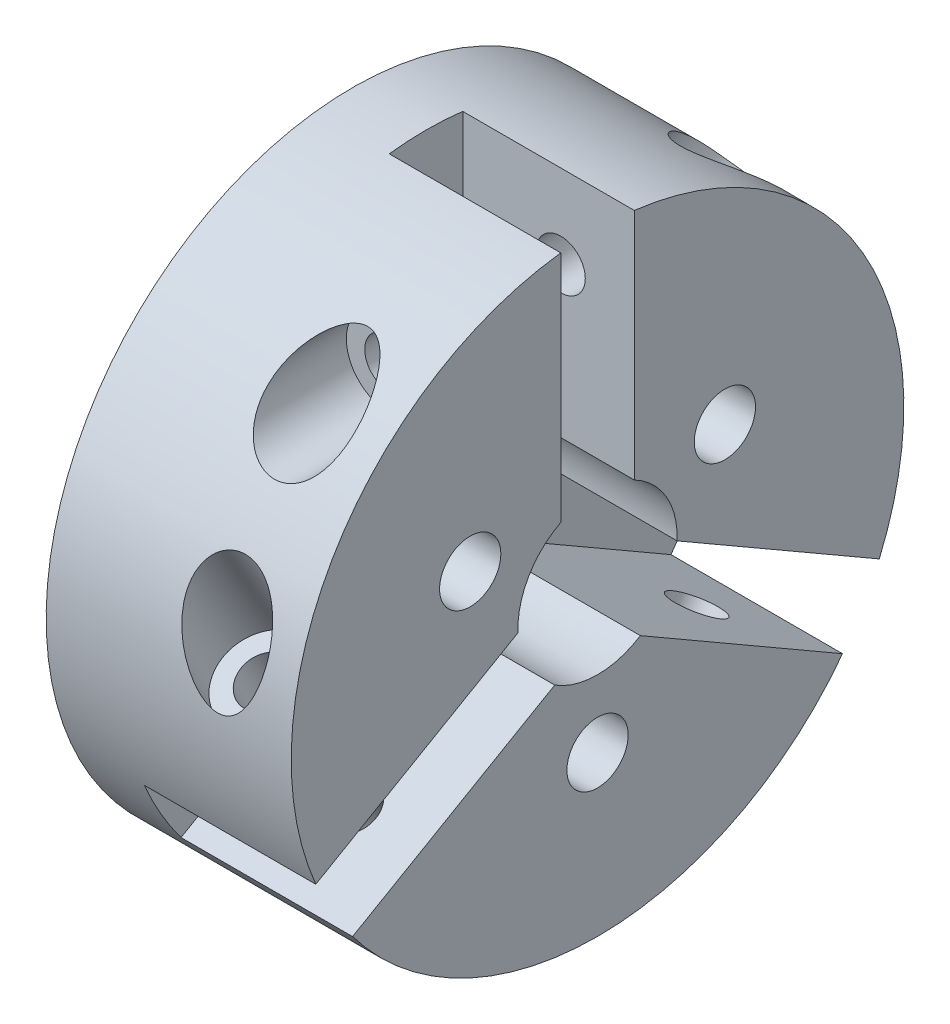
from build123d import *

# Parameters (mm, degrees)
SKETCH1_R           = 12.5
SKETCH1_R_2         = 32.5
BOSS_EXTRUDE1_DEPTH = 30
SKETCH1_3_R         = 12.5
BOSS_EXTRUDE2_DEPTH = 100
SKETCH5_R           = 10
SKETCH5_R_2         = 17.5
CUT_EXTRUDE1_DEPTH  = 95
SKETCH5_3_R         = 10
CUT_EXTRUDE2_DEPTH  = 150
CIRPATTERN1_COUNT   = 3
SKETCH6_R           = 10
SKETCH6_R_2         = 17.5
CUT_EXTRUDE3_DEPTH  = 80
SKETCH6_3_R         = 10
CUT_EXTRUDE4_DEPTH  = 150
CIRPATTERN2_COUNT   = 3


with BuildPart() as part:
    # Sketch1 → Boss-Extrude1 (new body)
    with BuildSketch(Plane(origin=(0, 0, 0), x_dir=(0, 0, -1), z_dir=(1, 0, 0))):
        with BuildLine():
            Line((-114.970926, -49.057987), (-32.46873, -1.425322))
            ThreePointArc((-32.46873, -1.425322), (-28.145826, 16.25), (-15, 28.831406))
            Line((-15, 28.831406), (-15, 124.096736))
            ThreePointArc((-15, 124.096736), (-108.253175, 62.5), (-114.970926, -49.057987))
        make_face()
        with Locations((-51.961524, 30)):
            Circle(SKETCH1_R, mode=Mode.SUBTRACT)
        with BuildLine():
            Line((-99.970926, -75.038749), (-17.46873, -27.406084))
            ThreePointArc((-17.46873, -27.406084), (-28.145826, -16.25), (-32.46873, -1.425322))
            Line((-32.46873, -1.425322), (-114.970926, -49.057987))
            ThreePointArc((-114.970926, -49.057987), (-108.253175, -62.5), (-99.970926, -75.038749))
        make_face()
        with BuildLine():
            Line((99.970926, -75.038749), (17.46873, -27.406084))
            ThreePointArc((17.46873, -27.406084), (0, -32.5), (-17.46873, -27.406084))
            Line((-17.46873, -27.406084), (-99.970926, -75.038749))
            ThreePointArc((-99.970926, -75.038749), (0, -125), (99.970926, -75.038749))
        make_face()
        with Locations((0, -60)):
            Circle(SKETCH1_R, mode=Mode.SUBTRACT)
        with BuildLine():
            ThreePointArc((32.46873, -1.425322), (28.145826, -16.25), (17.46873, -27.406084))
            Line((17.46873, -27.406084), (99.970926, -75.038749))
            ThreePointArc((99.970926, -75.038749), (108.253175, -62.5), (114.970926, -49.057987))
            Line((114.970926, -49.057987), (32.46873, -1.425322))
        make_face()
        with BuildLine():
            ThreePointArc((32.5, 0), (32.492182, -0.712833), (32.46873, -1.425322))
            Line((32.46873, -1.425322), (114.970926, -49.057987))
            ThreePointArc((114.970926, -49.057987), (122.467069, -25.036316), (125, 0))
            ThreePointArc((125, 0), (93.541435, 82.91562), (15, 124.096736))
            Line((15, 124.096736), (15, 28.831406))
            ThreePointArc((15, 28.831406), (27.782638, 16.863422), (32.5, 0))
        make_face()
        with Locations((51.961524, 30)):
            Circle(SKETCH1_R, mode=Mode.SUBTRACT)
        with BuildLine():
            Line((-15, 124.096736), (-15, 28.831406))
            ThreePointArc((-15, 28.831406), (0, 32.5), (15, 28.831406))
            Line((15, 28.831406), (15, 124.096736))
            ThreePointArc((15, 124.096736), (0, 125), (-15, 124.096736))
        make_face()
        Circle(SKETCH1_R_2)
    extrude(amount=BOSS_EXTRUDE1_DEPTH)

    # Sketch1_3 → Boss-Extrude2 (add)
    with BuildSketch(Plane(origin=(0, 0, 0), x_dir=(0, 0, -1), z_dir=(1, 0, 0))):
        with BuildLine():
            Line((-114.970926, -49.057987), (-32.46873, -1.425322))
            ThreePointArc((-32.46873, -1.425322), (-28.145826, 16.25), (-15, 28.831406))
            Line((-15, 28.831406), (-15, 124.096736))
            ThreePointArc((-15, 124.096736), (-108.253175, 62.5), (-114.970926, -49.057987))
        make_face()
        with Locations((-51.961524, 30)):
            Circle(SKETCH1_3_R, mode=Mode.SUBTRACT)
        with BuildLine():
            ThreePointArc((32.5, 0), (32.492182, -0.712833), (32.46873, -1.425322))
            Line((32.46873, -1.425322), (114.970926, -49.057987))
            ThreePointArc((114.970926, -49.057987), (122.467069, -25.036316), (125, 0))
            ThreePointArc((125, 0), (93.541435, 82.91562), (15, 124.096736))
            Line((15, 124.096736), (15, 28.831406))
            ThreePointArc((15, 28.831406), (27.782638, 16.863422), (32.5, 0))
        make_face()
        with Locations((51.961524, 30)):
            Circle(SKETCH1_3_R, mode=Mode.SUBTRACT)
        with BuildLine():
            Line((99.970926, -75.038749), (17.46873, -27.406084))
            ThreePointArc((17.46873, -27.406084), (0, -32.5), (-17.46873, -27.406084))
            Line((-17.46873, -27.406084), (-99.970926, -75.038749))
            ThreePointArc((-99.970926, -75.038749), (0, -125), (99.970926, -75.038749))
        make_face()
        with Locations((0, -60)):
            Circle(SKETCH1_3_R, mode=Mode.SUBTRACT)
    extrude(amount=BOSS_EXTRUDE2_DEPTH)

    # Sketch5 → Cut-Extrude1 (cut)
    with BuildSketch(Plane.XY.offset(-150)):
        with Locations((70, 90)):
            Circle(SKETCH5_R)
        with Locations((70, 90)):
            Circle(SKETCH5_R_2)
        with Locations((70, 90)):
            Circle(SKETCH5_R, mode=Mode.SUBTRACT)
    cut_extrude1 = extrude(amount=CUT_EXTRUDE1_DEPTH, mode=Mode.SUBTRACT)

    # Sketch5_3 → Cut-Extrude2 (cut)
    with BuildSketch(Plane.XY.offset(-150)):
        with Locations((70, 90)):
            Circle(SKETCH5_3_R)
    cut_extrude2 = extrude(amount=CUT_EXTRUDE2_DEPTH, mode=Mode.SUBTRACT)

    # CirPattern1: Cut-Extrude1, Cut-Extrude2 ×3 about axis
    cirpattern1_axis = Axis((0, 0, 0), (1, 0, 0))
    for i in range(1, CIRPATTERN1_COUNT):
        add(cut_extrude1.rotate(cirpattern1_axis, i * 360 / CIRPATTERN1_COUNT), mode=Mode.SUBTRACT)
        add(cut_extrude2.rotate(cirpattern1_axis, i * 360 / CIRPATTERN1_COUNT), mode=Mode.SUBTRACT)

    # Sketch6 → Cut-Extrude3 (cut)
    with BuildSketch(Plane(origin=(0, 116.91343, -67.5), x_dir=(1, 0, 0), z_dir=(0, 0.866025, -0.5))):
        with Locations((70, 90)):
            Circle(SKETCH6_R)
        with Locations((70, 90)):
            Circle(SKETCH6_R_2)
        with Locations((70, 90)):
            Circle(SKETCH6_R, mode=Mode.SUBTRACT)
    cut_extrude3 = extrude(amount=-CUT_EXTRUDE3_DEPTH, mode=Mode.SUBTRACT)

    # Sketch6_3 → Cut-Extrude4 (cut)
    with BuildSketch(Plane(origin=(0, 116.91343, -67.5), x_dir=(1, 0, 0), z_dir=(0, 0.866025, -0.5))):
        with Locations((70, 90)):
            Circle(SKETCH6_3_R)
    cut_extrude4 = extrude(amount=-CUT_EXTRUDE4_DEPTH, mode=Mode.SUBTRACT)

    # CirPattern2: Cut-Extrude3, Cut-Extrude4 ×3 about axis
    cirpattern2_axis = Axis((0, 0, 0), (1, 0, 0))
    for i in range(1, CIRPATTERN2_COUNT):
        add(cut_extrude3.rotate(cirpattern2_axis, i * 360 / CIRPATTERN2_COUNT), mode=Mode.SUBTRACT)
        add(cut_extrude4.rotate(cirpattern2_axis, i * 360 / CIRPATTERN2_COUNT), mode=Mode.SUBTRACT)


solid = part.part
